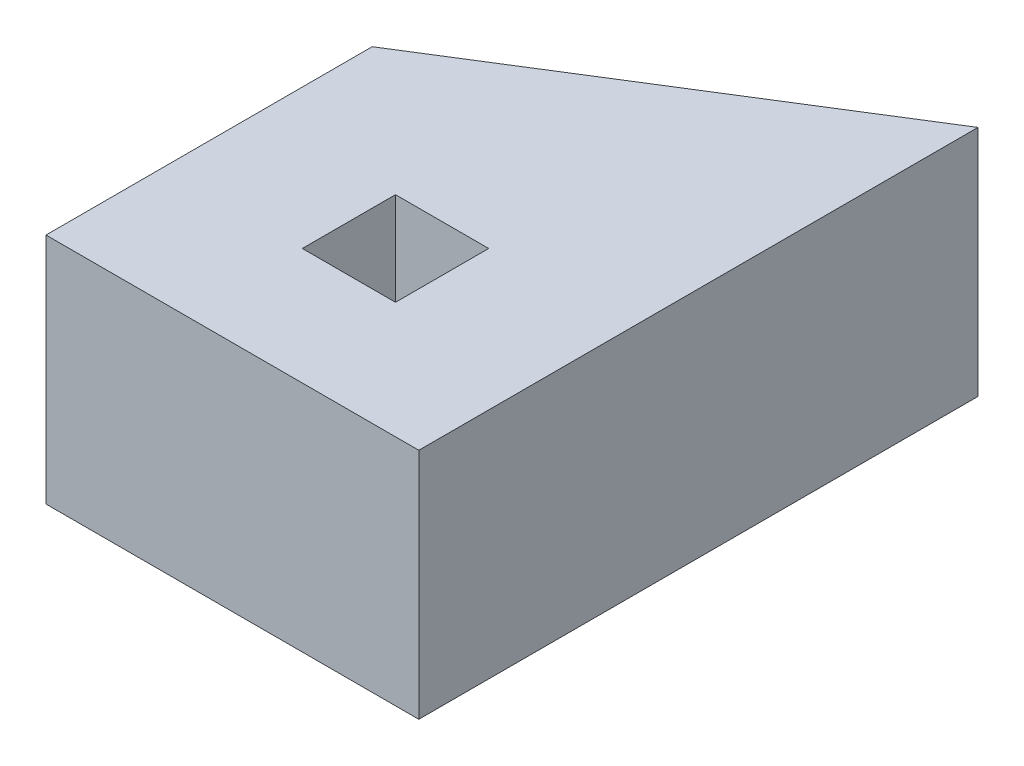
from build123d import *

# Parameters (mm, degrees)
SKETCH1_W           = 80
SKETCH1_H           = 70
BOSS_EXTRUDE1_DEPTH = 50
SKETCH2_W           = 20
SKETCH2_H           = 20
CUT_EXTRUDE1_DEPTH  = 51


with BuildPart() as part:
    # Sketch1 → Boss-Extrude1 (new body)
    with BuildSketch(Plane(origin=(0, 0, 0), x_dir=(1, 0, 0), z_dir=(0, 1, 0))):
        Rectangle(SKETCH1_W, SKETCH1_H)
        Polygon((40, 35), (40, 85), (-40, 35), align=None)
    extrude(amount=BOSS_EXTRUDE1_DEPTH)

    # Sketch2 → Cut-Extrude1 (cut, through all)
    with BuildSketch(Plane(origin=(0, 50, 0), x_dir=(1, 0, 0), z_dir=(0, 1, 0))):
        Rectangle(SKETCH2_W, SKETCH2_H)
    extrude(amount=-CUT_EXTRUDE1_DEPTH, mode=Mode.SUBTRACT)


solid = part.part
